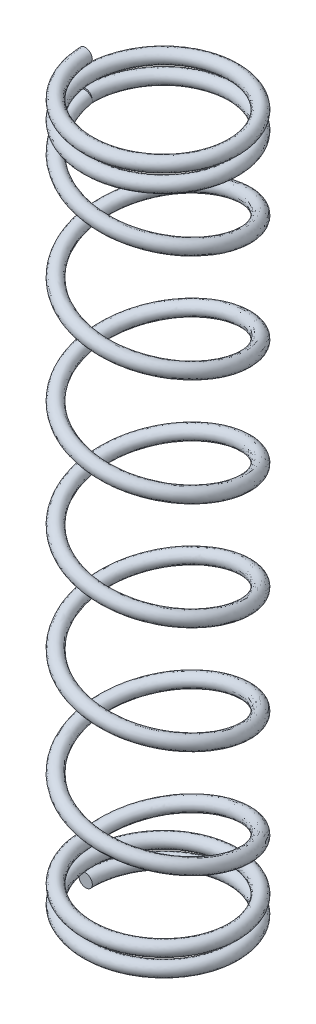
from build123d import *

# Parameters (mm, degrees)
SWEEP1_PITCH       = 0.66
SWEEP1_HEIGHT      = 1.32
SWEEP1_RADIUS      = 2.7
SWEEP1_START_ANGLE = -90
SWEEP1_PROFILE_R   = 0.25
SWEEP2_PITCH       = 4
SWEEP2_HEIGHT      = 24
SWEEP2_RADIUS      = 2.7
SWEEP2_START_ANGLE = -90
SWEEP2_PROFILE_R   = 0.25
SWEEP3_PITCH       = 0.66
SWEEP3_HEIGHT      = 1.32
SWEEP3_RADIUS      = 2.698299711
SWEEP3_START_ANGLE = -90
SWEEP3_PROFILE_R   = 0.25


with BuildPart() as part:
    # Sweep1: sweep along a helix
    with BuildLine() as sweep1_path:
        add(Helix(SWEEP1_PITCH, SWEEP1_HEIGHT, SWEEP1_RADIUS, center=(0, 24, 0), direction=(0, 1, 0), lefthand=True, mode=Mode.PRIVATE).rotate(Axis((0, 24, 0), (0, 1, 0)), SWEEP1_START_ANGLE))
    # Sweep1 profile (on start of the path) → Sweep1 (sweep)
    with BuildSketch(Plane(origin=(-2.7, 24, 0), x_dir=(0, -0.9992440763153999, -0.038875132778979866), z_dir=(1.108448112333572e-13, 0.038875132778979866, -0.9992440763153999))):
        Circle(SWEEP1_PROFILE_R)
    sweep(path=sweep1_path.line, is_frenet=True)

    # Sweep2: sweep along a helix
    with BuildLine() as sweep2_path:
        add(Helix(SWEEP2_PITCH, SWEEP2_HEIGHT, SWEEP2_RADIUS, center=(0, 0, 0), direction=(0, 1, 0), lefthand=True, mode=Mode.PRIVATE).rotate(Axis((0, 0, 0), (0, 1, 0)), SWEEP2_START_ANGLE))
    # Sweep2 profile (on start of the path) → Sweep2 (sweep)
    with BuildSketch(Plane(origin=(-2.7, 0, 0), x_dir=(0, -0.9733105194690093, -0.2294921190171191), z_dir=(-2.7327419733729754e-13, 0.2294921190171191, -0.9733105194690093))):
        Circle(SWEEP2_PROFILE_R)
    sweep(path=sweep2_path.line, is_frenet=True)

    # Sweep3: sweep along a helix
    with BuildLine() as sweep3_path:
        add(Helix(SWEEP3_PITCH, SWEEP3_HEIGHT, SWEEP3_RADIUS, center=(0, 0, 0), direction=(0, -1, 0), lefthand=True, mode=Mode.PRIVATE).rotate(Axis((0, 0, 0), (0, -1, 0)), SWEEP3_START_ANGLE))
    # Sweep3 profile (on start of the path) → Sweep3 (sweep)
    with BuildSketch(Plane(origin=(-2.698299711, 0, 0), x_dir=(0, 0.9992431244311905, 0.03889959224712199), z_dir=(-3.254250427122736e-13, -0.03889959224712199, 0.9992431244311905))):
        Circle(SWEEP3_PROFILE_R)
    sweep(path=sweep3_path.line, is_frenet=True)


solid = part.part
